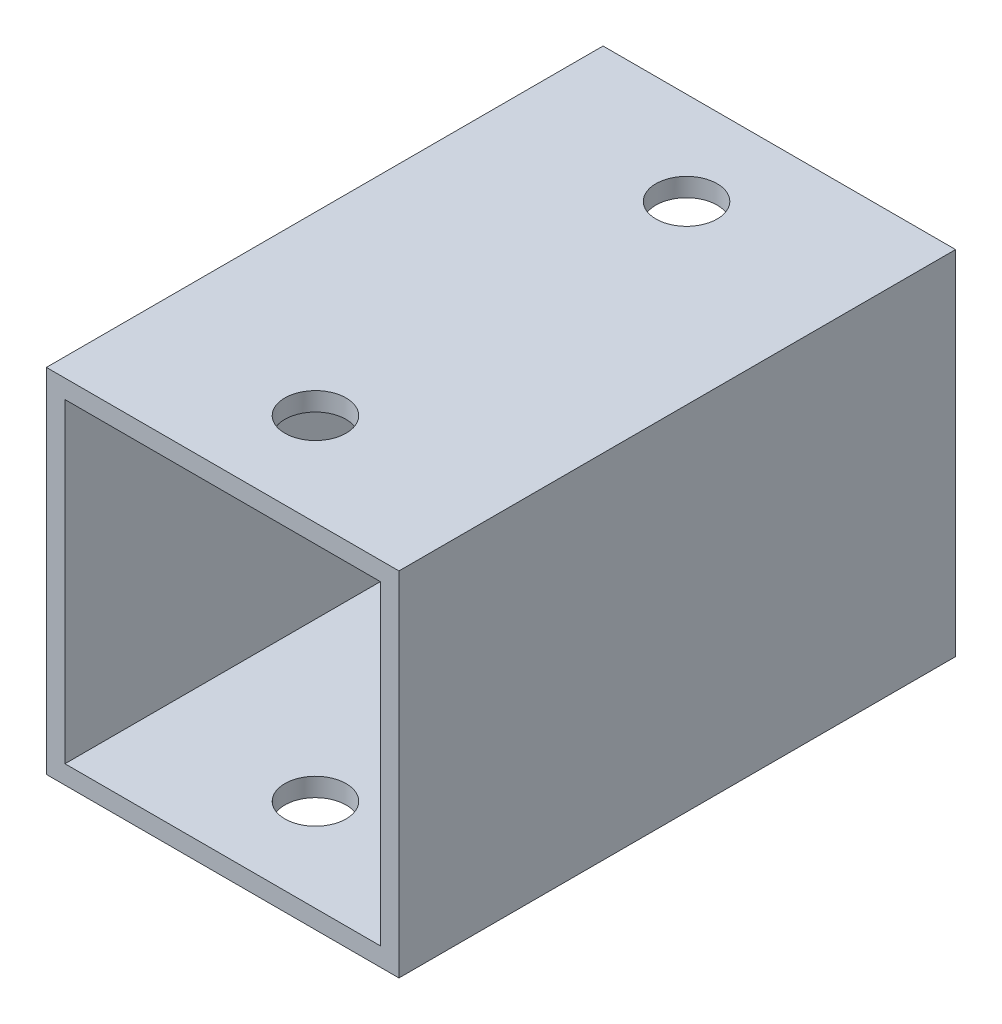
from build123d import *

# Parameters (mm, degrees)
ESBO_O1_W                = 19
ESBO_O1_H                = 19
RESSALTO_EXTRUS_O1_DEPTH = 30
CASCA1_T                 = -1
ESBO_O2_R                = 1.65
CORTE_EXTRUS_O1_DEPTH    = 20


with BuildPart() as part:
    # Esboço1 → Ressalto-extrusão1 (new body)
    with BuildSketch(Plane.XY):
        with Locations((9.5, 9.5)):
            Rectangle(ESBO_O1_W, ESBO_O1_H)
    extrude(amount=RESSALTO_EXTRUS_O1_DEPTH)

    # Casca1
    casca1_openings = [part.faces().sort_by_distance(p)[0] for p in [
        (9.5, 9.5, 30),
        (9.5, 9.5, 0),
    ]]
    offset(amount=CASCA1_T, openings=casca1_openings, kind=Kind.INTERSECTION)

    # Esboço2 → Corte-extrusão1 (cut, through all)
    with BuildSketch(Plane(origin=(0, 19, 0), x_dir=(1, 0, 0), z_dir=(0, 1, 0))):
        with Locations((9.5, -25)):
            Circle(ESBO_O2_R)
        with Locations((9.5, -5)):
            Circle(ESBO_O2_R)
    extrude(amount=-CORTE_EXTRUS_O1_DEPTH, mode=Mode.SUBTRACT)


solid = part.part
